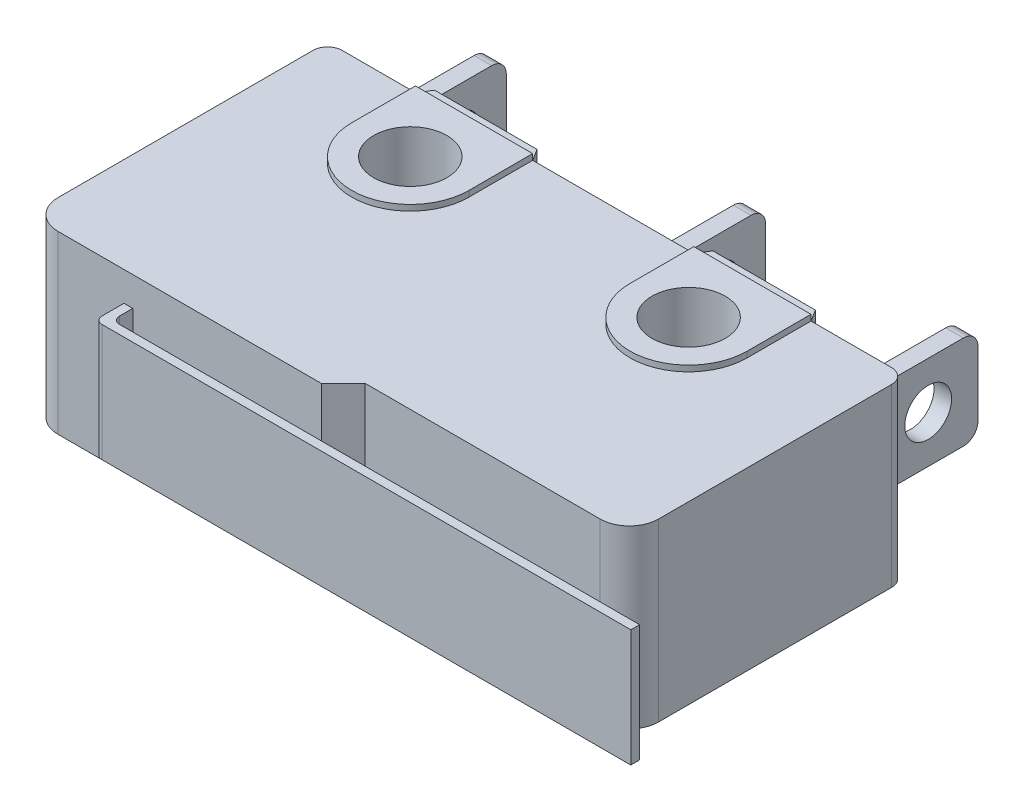
from build123d import *

# Parameters (mm, degrees)
BOSS_EXTRUDE1_DEPTH      = 3
BOSS_EXTRUDE1_DEPTH_BACK = 3
BOSS_EXTRUDE2_DEPTH      = 2
BOSS_EXTRUDE2_DEPTH_BACK = 2
BOSS_EXTRUDE3_DEPTH      = 3.2
BOSS_EXTRUDE3_DEPTH_BACK = 3.2
CUT_EXTRUDE1_DEPTH       = 15.583683419
CUT_EXTRUDE1_DEPTH_BACK  = 15.583683419
SKETCH3_R                = 1.25
BOSS_EXTRUDE4_DEPTH      = 3
BOSS_EXTRUDE4_DEPTH_BACK = 3
BOSS_EXTRUDE5_DEPTH      = 1.6
BOSS_EXTRUDE5_DEPTH_BACK = 1.6
SKETCH6_W                = 0.6
SKETCH6_H                = 4
FILLET1_R                = 0.5
CUT_EXTRUDE2_DEPTH       = 23.258777665
CUT_EXTRUDE2_DEPTH_BACK  = 23.258777665
SKETCH7_R                = 0.8


with BuildPart() as part:
    # Sketch1 → Boss-Extrude1 (new, two sides: drawn at the far end of the back side and taken through both)
    with BuildSketch(Plane(origin=(0, 0, 0), x_dir=(1, 0, 0), z_dir=(0, 1, 0)).offset(-BOSS_EXTRUDE1_DEPTH_BACK)):
        with BuildLine():
            Line((-8.832423279, -5.07801101), (0.167576721, -5.07801101))
            Line((0.167576721, -5.07801101), (0.89698899, -4.32801101))
            Line((0.89698899, -4.32801101), (8.917576721, -4.32801101))
            ThreePointArc((8.917576721, -4.32801101), (9.624683502, -4.035117791), (9.917576721, -3.32801101))
            Line((9.917576721, -3.32801101), (9.917576721, 4.62198899))
            ThreePointArc((9.917576721, 4.62198899), (9.771130112, 4.975542381), (9.417576721, 5.12198899))
            Line((9.417576721, 5.12198899), (-9.332423279, 5.12198899))
            ThreePointArc((-9.332423279, 5.12198899), (-9.685976669, 4.975542381), (-9.832423279, 4.62198899))
            Line((-9.832423279, 4.62198899), (-9.832423279, -4.07801101))
            ThreePointArc((-9.832423279, -4.07801101), (-9.53953006, -4.785117791), (-8.832423279, -5.07801101))
        make_face()
    extrude(amount=BOSS_EXTRUDE1_DEPTH + BOSS_EXTRUDE1_DEPTH_BACK)

    # Sketch2 → Boss-Extrude2 (add, two sides: drawn at the far end of the back side and taken through both)
    with BuildSketch(Plane(origin=(0, 0, 0), x_dir=(1, 0, 0), z_dir=(0, 1, 0)).offset(-BOSS_EXTRUDE2_DEPTH_BACK)):
        with BuildLine():
            Line((-6.582423279, -5.07801101), (-6.282423279, -5.07801101))
            Line((-6.282423279, -5.07801101), (-6.282423279, -5.52801101))
            ThreePointArc((-6.282423279, -5.52801101), (-6.209199974, -5.704787705), (-6.032423279, -5.77801101))
            Line((-6.032423279, -5.77801101), (11.717576721, -5.77801101))
            Line((11.717576721, -5.77801101), (11.717576721, -6.07801101))
            Line((11.717576721, -6.07801101), (-6.282423279, -6.07801101))
            Line((-6.282423279, -6.07801101), (-6.332423279, -6.07801101))
            ThreePointArc((-6.332423279, -6.07801101), (-6.509199974, -6.004787705), (-6.582423279, -5.82801101))
            Line((-6.582423279, -5.82801101), (-6.582423279, -5.07801101))
        make_face()
    extrude(amount=BOSS_EXTRUDE2_DEPTH + BOSS_EXTRUDE2_DEPTH_BACK)

    # Sketch4 → Boss-Extrude3 (add, two sides: drawn at the far end of the back side and taken through both)
    with BuildSketch(Plane(origin=(0, 0, 0), x_dir=(1, 0, 0), z_dir=(0, 1, 0)).offset(-BOSS_EXTRUDE3_DEPTH_BACK)):
        with BuildLine():
            Line((-6.832423279, 2.944690743), (-6.832423279, 5.12198899))
            Line((-6.832423279, 5.12198899), (-2.832423279, 5.12198899))
            Line((-2.832423279, 5.12198899), (-2.832423279, 2.944690743))
            ThreePointArc((-2.832423279, 2.944690743), (-4.832423279, 0.944690743), (-6.832423279, 2.944690743))
        make_face()
        with BuildLine():
            Line((6.667576721, 5.12198899), (6.667576721, 2.944690743))
            ThreePointArc((6.667576721, 2.944690743), (4.667576721, 0.944690743), (2.667576721, 2.944690743))
            Line((2.667576721, 2.944690743), (2.667576721, 5.12198899))
            Line((2.667576721, 5.12198899), (6.667576721, 5.12198899))
        make_face()
    extrude(amount=BOSS_EXTRUDE3_DEPTH + BOSS_EXTRUDE3_DEPTH_BACK)

    # Sketch3 → Cut-Extrude1 (cut, two sides: drawn at the far end of the back side and taken through both)
    with BuildSketch(Plane(origin=(0, 3, 0), x_dir=(1, 0, 0), z_dir=(0, 1, 0)).offset(-CUT_EXTRUDE1_DEPTH_BACK)):
        with Locations((-4.832423279, 2.944690743)):
            Circle(SKETCH3_R)
        with Locations((4.667576721, 2.944690743)):
            Circle(SKETCH3_R)
    extrude(amount=CUT_EXTRUDE1_DEPTH + CUT_EXTRUDE1_DEPTH_BACK, mode=Mode.SUBTRACT)

    # Sketch5 → Boss-Extrude4 (add, two sides: drawn at the far end of the back side and taken through both)
    with BuildSketch(Plane(origin=(0, 0, 0), x_dir=(1, 0, 0), z_dir=(0, 1, 0)).offset(-BOSS_EXTRUDE4_DEPTH_BACK)):
        Polygon((-6.832423279, 5.12198899), (-2.832423279, 5.12198899), (-3.082423279, 5.52198899), (-6.582423279, 5.52198899), align=None)
        Polygon((6.417576721, 5.52198899), (6.667576721, 5.12198899), (2.667576721, 5.12198899), (2.917576721, 5.52198899), align=None)
    extrude(amount=BOSS_EXTRUDE4_DEPTH + BOSS_EXTRUDE4_DEPTH_BACK)

    # Sketch6 → Boss-Extrude5 (add, two sides: drawn at the far end of the back side and taken through both)
    with BuildSketch(Plane(origin=(0, 0, 0), x_dir=(1, 0, 0), z_dir=(0, 1, 0)).offset(-BOSS_EXTRUDE5_DEPTH_BACK)):
        with Locations((-8.032423279, 7.12198899)):
            Rectangle(SKETCH6_W, SKETCH6_H)
        with Locations((0.817576721, 7.12198899)):
            Rectangle(SKETCH6_W, SKETCH6_H)
        with Locations((8.067576721, 7.12198899)):
            Rectangle(SKETCH6_W, SKETCH6_H)
    extrude(amount=BOSS_EXTRUDE5_DEPTH + BOSS_EXTRUDE5_DEPTH_BACK)

    # Fillet1
    fillet1_edges = [part.edges().sort_by_distance(p)[0] for p in [
        (-8.032423279, -1.6, -9.12198899),
        (0.817576721, -1.6, -9.12198899),
        (8.067576721, -1.6, -9.12198899),
        (8.067576721, 1.6, -9.12198899),
        (0.817576721, 1.6, -9.12198899),
        (-8.032423279, 1.6, -9.12198899),
    ]]
    fillet(fillet1_edges, radius=FILLET1_R)

    # Sketch7 → Cut-Extrude2 (cut, two sides: drawn at the far end of the back side and taken through both)
    with BuildSketch(Plane.ZY.offset(8.332423279).offset(-CUT_EXTRUDE2_DEPTH_BACK)):
        with Locations((-7.42198899, 0)):
            Circle(SKETCH7_R)
    extrude(amount=CUT_EXTRUDE2_DEPTH + CUT_EXTRUDE2_DEPTH_BACK, mode=Mode.SUBTRACT)


solid = part.part
